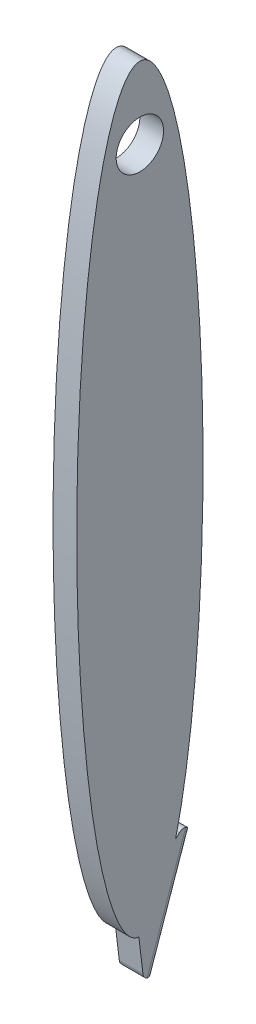
from build123d import *

# Parameters (mm, degrees)
SKETCH1_RX          = 76.2
SKETCH1_RY          = 12.7
BOSS_EXTRUDE1_DEPTH = 4.7625
BOSS_EXTRUDE2_DEPTH = 4.7625
FILLET7_R           = 1.27
SKETCH3_R           = 4.7625
CUT_EXTRUDE1_DEPTH  = 5.7625001


with BuildPart() as part:
    # Sketch1 → Boss-Extrude1 (new body)
    with BuildSketch(Plane(origin=(0, 0, 0), x_dir=(0, 0, -1), z_dir=(1, 0, 0))):
        with Locations(Location((0, 0), (0, 0, 90))):
            Ellipse(SKETCH1_RX, SKETCH1_RY)
    extrude(amount=BOSS_EXTRUDE1_DEPTH)

    # Sketch2 → Boss-Extrude2 (add)
    with BuildSketch(Plane(origin=(0, 0, 0), x_dir=(0, 0, -1), z_dir=(1, 0, 0))):
        Polygon((-0.911321498, -70.388673766), (1.299359703, -88.563738569), (11.69809992, -58.590129834), align=None)
    extrude(amount=BOSS_EXTRUDE2_DEPTH)

    # Fillet7
    fillet7_edges = [part.edges().sort_by_distance(p)[0] for p in [
        (2.38125, -58.590129834, -11.69809992),
        (0, -73.576934201, -6.498729811),
        (2.38125, -88.563738569, -1.299359703),
        (4.7625, -73.576934201, -6.498729811),
    ]]
    fillet(fillet7_edges, radius=FILLET7_R)

    # Sketch3 → Cut-Extrude1 (cut, through all)
    with BuildSketch(Plane(origin=(4.7625, 0, 0), x_dir=(0, 0, -1), z_dir=(1, 0, 0))):
        with Locations((0, 61.704213054)):
            Circle(SKETCH3_R)
    extrude(amount=-CUT_EXTRUDE1_DEPTH, mode=Mode.SUBTRACT)


solid = part.part
